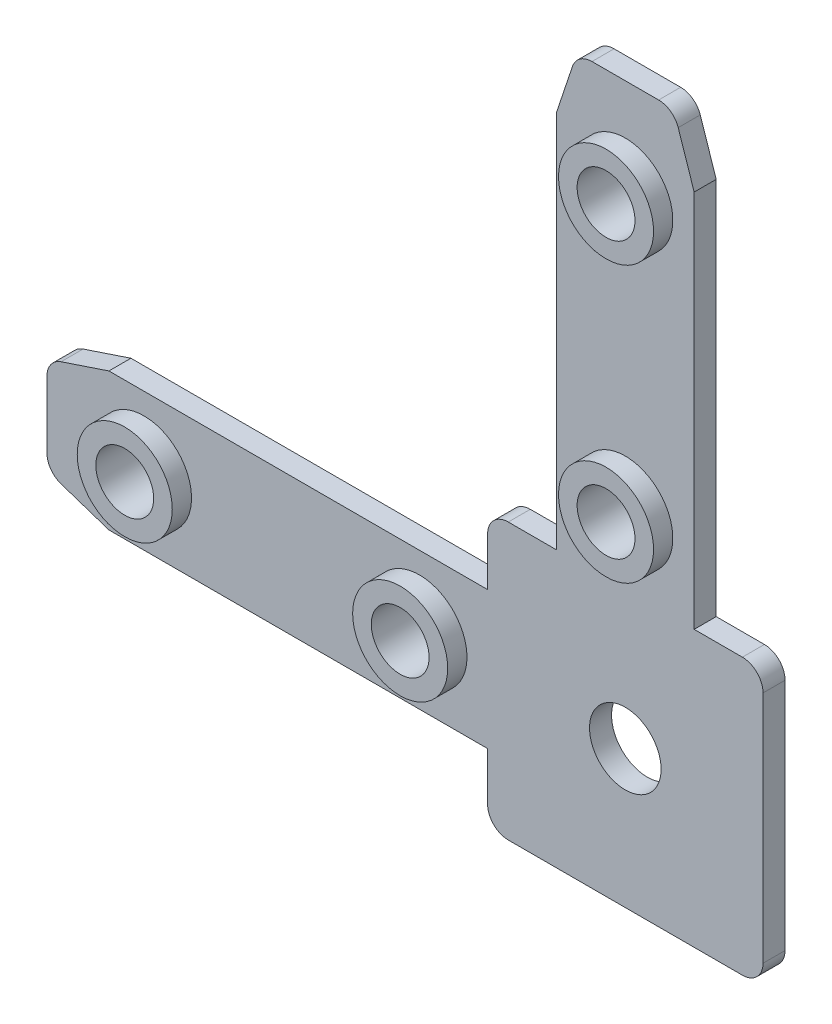
from build123d import *

# Parameters (mm, degrees)
SKETCH1_R             = 2.6
BOSS_EXTRUDE1_DEPTH   = 1.6
SKETCH2_R             = 3.45
BOSS_EXTRUDE2_DEPTH   = 1.4
M5X0_8_TAPPED_HOLE1_D = 4.2


with BuildPart() as part:
    # Sketch1 → Boss-Extrude1 (new body)
    with BuildSketch(Plane.XY):
        with BuildLine():
            Line((-10, -8.5), (-10, -5))
            Line((-10, -5), (-37.5, -5))
            Line((-37.5, -5), (-40.974341649, -3.841886117))
            ThreePointArc((-40.974341649, -3.841886117), (-41.716863278, -3.295926597), (-42, -2.41886117))
            Line((-42, -2.41886117), (-42, 2.41886117))
            ThreePointArc((-42, 2.41886117), (-41.716863278, 3.295926597), (-40.974341649, 3.841886117))
            Line((-40.974341649, 3.841886117), (-37.5, 5))
            Line((-37.5, 5), (-10, 5))
            Line((-10, 5), (-10, 8.5))
            ThreePointArc((-10, 8.5), (-9.560660172, 9.560660172), (-8.5, 10))
            Line((-8.5, 10), (-5, 10))
            Line((-5, 10), (-5, 37.5))
            Line((-5, 37.5), (-3.841886117, 40.974341649))
            ThreePointArc((-3.841886117, 40.974341649), (-3.295926597, 41.716863278), (-2.41886117, 42))
            Line((-2.41886117, 42), (2.41886117, 42))
            ThreePointArc((2.41886117, 42), (3.295926597, 41.716863278), (3.841886117, 40.974341649))
            Line((3.841886117, 40.974341649), (5, 37.5))
            Line((5, 37.5), (5, 10))
            Line((5, 10), (8.5, 10))
            ThreePointArc((8.5, 10), (9.560660172, 9.560660172), (10, 8.5))
            Line((10, 8.5), (10, -8.5))
            ThreePointArc((10, -8.5), (9.560660172, -9.560660172), (8.5, -10))
            Line((8.5, -10), (5, -10))
            Line((5, -10), (-5, -10))
            Line((-5, -10), (-8.5, -10))
            ThreePointArc((-8.5, -10), (-9.560660172, -9.560660172), (-10, -8.5))
        make_face()
        Circle(SKETCH1_R, mode=Mode.SUBTRACT)
    extrude(amount=BOSS_EXTRUDE1_DEPTH)

    # Sketch2 → Boss-Extrude2 (add)
    with BuildSketch(Plane.XY.offset(1.6)):
        with Locations((0, 14.95)):
            Circle(SKETCH2_R)
        with Locations((0, 34.95)):
            Circle(SKETCH2_R)
        with Locations((-14.95, 0)):
            Circle(SKETCH2_R)
        with Locations((-34.95, 0)):
            Circle(SKETCH2_R)
    extrude(amount=BOSS_EXTRUDE2_DEPTH)

    # M5x0.8 Tapped Hole1 (through all)
    with Locations(Plane.XY.offset(3)):
        with Locations((0, 34.95), (0, 14.95), (-14.95, 0), (-34.95, 0)):
            Hole(M5X0_8_TAPPED_HOLE1_D / 2)


solid = part.part
